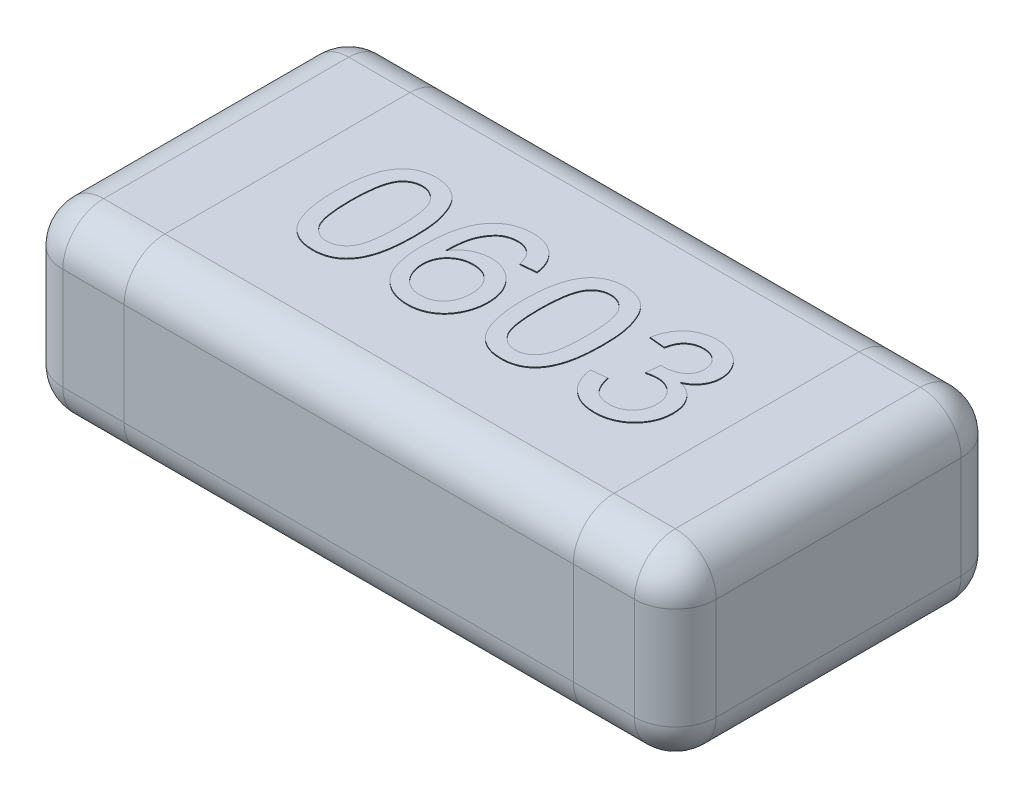
from build123d import *

# Parameters (mm, degrees)
SKETCH1_W      = 1.6
SKETCH1_H      = 0.8
EXTRUDE1_DEPTH = 0.45
FILLET1_R      = 0.1
EXTRUDE2_DEPTH = 0.002


with BuildPart() as part:
    # Sketch1 → Extrude1 (new body)
    with BuildSketch(Plane(origin=(0, 0, 0), x_dir=(1, 0, 0), z_dir=(0, 1, 0))):
        Rectangle(SKETCH1_W, SKETCH1_H)
    extrude(amount=EXTRUDE1_DEPTH)

    # Fillet1
    fillet1_edges = [part.edges().sort_by_distance(p)[0] for p in [
        (0.8, 0.45, 0),
        (0, 0.45, -0.4),
        (-0.8, 0.45, 0),
        (0, 0, -0.4),
        (0.8, 0, 0),
        (0, 0, 0.4),
        (-0.8, 0, 0),
        (0, 0.45, 0.4),
        (-0.8, 0.225, -0.4),
        (0.8, 0.225, -0.4),
        (0.8, 0.225, 0.4),
        (-0.8, 0.225, 0.4),
    ]]
    fillet(fillet1_edges, radius=FILLET1_R)

    # Sketch3 → Extrude2 (add)
    with BuildSketch(Plane(origin=(0, 0.45, 0), x_dir=(1, 0, 0), z_dir=(0, 1, 0))):
        with BuildLine():
            add(Edge.make_bspline(
                [(-0.430769231, -0.002043269), (-0.430730481, 0.002244006), (-0.430654586, 0.010640973), (-0.430183834, 0.022927244), (-0.42936194, 0.034595007), (-0.428135078, 0.045634129), (-0.426682243, 0.056069528), (-0.424793549, 0.06588631), (-0.422668494, 0.075106502), (-0.420118809, 0.083720493), (-0.41731754, 0.091802347), (-0.414139411, 0.0993391), (-0.410563584, 0.106322761), (-0.40676579, 0.112825754), (-0.402546105, 0.118746931), (-0.39815922, 0.124252464), (-0.393286323, 0.129140445), (-0.388130039, 0.13353664), (-0.382614442, 0.137416027), (-0.376768712, 0.140763469), (-0.370615345, 0.143719019), (-0.364037062, 0.145943957), (-0.357170429, 0.147757753), (-0.349962588, 0.149092003), (-0.342405598, 0.149878588), (-0.337241458, 0.149959072), (-0.334615385, 0.15)],
                knots=[0, 0, 0, 0, 1.2862e-05, 2.5191e-05, 3.688e-05, 4.7943e-05, 5.8507e-05, 6.8478e-05, 7.7924e-05, 8.6881e-05, 9.5415e-05, 0.000103574, 0.000111395, 0.00011894, 0.000126142, 0.000133191, 0.000140033, 0.000146812, 0.000153498, 0.000160229, 0.000167003, 0.000173941, 0.000181025, 0.000188297, 0.00019591, 0.000203786, 0.000203786, 0.000203786, 0.000203786], degree=3))
            add(Edge.make_bspline(
                [(-0.334615385, 0.15), (-0.330762593, 0.149886731), (-0.32319363, 0.149664209), (-0.312142905, 0.147849358), (-0.301728309, 0.144744777), (-0.291956608, 0.140556563), (-0.282994848, 0.135236725), (-0.274991618, 0.128769652), (-0.268033247, 0.121223246), (-0.262195674, 0.112508085), (-0.257093053, 0.102864591), (-0.252559996, 0.092249481), (-0.248462244, 0.080674651), (-0.24555439, 0.070313561), (-0.243480221, 0.061369501), (-0.242107285, 0.053992694), (-0.240967473, 0.046033077), (-0.240094223, 0.037509907), (-0.239377743, 0.028432744), (-0.238824437, 0.018795935), (-0.238543578, 0.008575397), (-0.238489398, 0.001562641), (-0.238461538, -0.002043269)],
                knots=[0, 0, 0, 0, 1.1554e-05, 2.2698e-05, 3.348e-05, 4.4085e-05, 5.4516e-05, 6.4643e-05, 7.485e-05, 8.5185e-05, 9.602e-05, 0.000107541, 0.000119781, 0.000132832, 0.000139801, 0.000147321, 0.000155335, 0.000163916, 0.000173019, 0.00018265, 0.000192871, 0.000203689, 0.000203689, 0.000203689, 0.000203689], degree=3))
            add(Edge.make_bspline(
                [(-0.238461538, -0.002043269), (-0.238501014, -0.006310407), (-0.238578138, -0.0146471), (-0.239036276, -0.026834856), (-0.239907695, -0.038414591), (-0.240979992, -0.049412832), (-0.242602154, -0.059800218), (-0.24435012, -0.069620882), (-0.246511923, -0.07883023), (-0.249034239, -0.087432298), (-0.251874941, -0.095472571), (-0.254990209, -0.103011813), (-0.258440668, -0.110044871), (-0.262329015, -0.11650315), (-0.266477343, -0.122472371), (-0.270916032, -0.127974928), (-0.275739189, -0.132931621), (-0.280941938, -0.137314631), (-0.28641881, -0.141262812), (-0.292278751, -0.144643304), (-0.298496114, -0.147443983), (-0.305029358, -0.149838424), (-0.311944772, -0.15159293), (-0.319187822, -0.152935977), (-0.326785196, -0.153726861), (-0.331969311, -0.153805841), (-0.334615385, -0.153846154)],
                knots=[0, 0, 0, 0, 1.2802e-05, 2.5011e-05, 3.658e-05, 4.7637e-05, 5.815e-05, 6.811e-05, 7.7556e-05, 8.6513e-05, 9.499e-05, 0.000103126, 0.000110974, 0.000118467, 0.000125719, 0.000132767, 0.000139652, 0.000146431, 0.000153152, 0.000159883, 0.000166686, 0.000173587, 0.000180729, 0.000188061, 0.000195673, 0.00020361, 0.00020361, 0.00020361, 0.00020361], degree=3))
            add(Edge.make_bspline(
                [(-0.334615385, -0.153846154), (-0.338084694, -0.153747192), (-0.344848894, -0.153554242), (-0.354727508, -0.152243272), (-0.363999114, -0.149935902), (-0.372741914, -0.146841394), (-0.380857634, -0.142702311), (-0.388385026, -0.137666308), (-0.395475345, -0.131850554), (-0.399556964, -0.127262057), (-0.401622596, -0.124939904)],
                knots=[0, 0, 0, 0, 1.0408e-05, 2.0292e-05, 2.9825e-05, 3.9025e-05, 4.8056e-05, 5.7073e-05, 6.616e-05, 7.5471e-05, 7.5471e-05, 7.5471e-05, 7.5471e-05], degree=3))
            add(Edge.make_bspline(
                [(-0.401622596, -0.124939904), (-0.404000186, -0.121510195), (-0.408902879, -0.11443799), (-0.414641055, -0.102379223), (-0.41975961, -0.089104214), (-0.423776737, -0.074352508), (-0.426923149, -0.058241513), (-0.429195644, -0.040739616), (-0.430481652, -0.021854376), (-0.430671207, -0.008796046), (-0.430769231, -0.002043269)],
                knots=[0, 0, 0, 0, 1.2501e-05, 2.5778e-05, 3.993e-05, 5.5152e-05, 7.157e-05, 8.9147e-05, 0.000108063, 0.000128321, 0.000128321, 0.000128321, 0.000128321], degree=3))
        make_face()
        with BuildLine():
            add(Edge.make_bspline(
                [(-0.392307692, -0.001923077), (-0.392269503, -0.007693168), (-0.3921964, -0.018738399), (-0.391432655, -0.034518417), (-0.390117899, -0.048754147), (-0.388379705, -0.061425879), (-0.386084585, -0.072550754), (-0.383202791, -0.082100422), (-0.379954324, -0.090189501), (-0.375934407, -0.096717734), (-0.371533042, -0.102039196), (-0.366988934, -0.106615825), (-0.362195175, -0.110505855), (-0.357183043, -0.113749347), (-0.351874773, -0.116205105), (-0.346328409, -0.117985045), (-0.340542745, -0.119009373), (-0.336602445, -0.119156549), (-0.334615385, -0.119230769)],
                knots=[0, 0, 0, 0, 1.7309e-05, 3.3134e-05, 4.7378e-05, 6.0186e-05, 7.1489e-05, 8.1413e-05, 9.0085e-05, 9.7558e-05, 0.000104306, 0.000110765, 0.000116876, 0.000122794, 0.000128628, 0.000134368, 0.000140227, 0.000146187, 0.000146187, 0.000146187, 0.000146187], degree=3))
            add(Edge.make_bspline(
                [(-0.334615385, -0.119230769), (-0.332628822, -0.119154928), (-0.328689509, -0.119004535), (-0.322890476, -0.118002795), (-0.317365692, -0.116131225), (-0.312065336, -0.11368414), (-0.307016775, -0.110514577), (-0.30224656, -0.106609854), (-0.297678514, -0.102035942), (-0.29329692, -0.096652628), (-0.289307629, -0.090094213), (-0.285998225, -0.082011723), (-0.283161342, -0.072445331), (-0.280853628, -0.061326124), (-0.279108264, -0.048674427), (-0.277801457, -0.03447818), (-0.2770326, -0.018718466), (-0.276960704, -0.007693194), (-0.276923077, -0.001923077)],
                knots=[0, 0, 0, 0, 5.96e-06, 1.1819e-05, 1.7578e-05, 2.3412e-05, 2.9298e-05, 3.5408e-05, 4.1867e-05, 4.8662e-05, 5.6186e-05, 6.4803e-05, 7.4784e-05, 8.6088e-05, 9.8836e-05, 0.00011308, 0.000128845, 0.000146154, 0.000146154, 0.000146154, 0.000146154], degree=3))
            add(Edge.make_bspline(
                [(-0.276923077, -0.001923077), (-0.276959499, 0.003726983), (-0.277029283, 0.014552283), (-0.27781797, 0.030028299), (-0.279053912, 0.044025088), (-0.280744486, 0.056555555), (-0.282991257, 0.067606095), (-0.285716284, 0.077200235), (-0.288963562, 0.085317512), (-0.292824563, 0.092039466), (-0.29712263, 0.097553292), (-0.301612368, 0.102325988), (-0.306406022, 0.10638501), (-0.31158852, 0.109641218), (-0.316992821, 0.112268205), (-0.322743102, 0.114076165), (-0.328782842, 0.115186918), (-0.332927837, 0.115317963), (-0.335036058, 0.115384615)],
                knots=[0, 0, 0, 0, 1.6949e-05, 3.2473e-05, 4.6473e-05, 5.9094e-05, 7.0385e-05, 8.0274e-05, 8.8979e-05, 9.6545e-05, 0.000103444, 0.000109906, 0.000116177, 0.000122229, 0.000128223, 0.000134153, 0.000140259, 0.000146579, 0.000146579, 0.000146579, 0.000146579], degree=3))
            add(Edge.make_bspline(
                [(-0.335036058, 0.115384615), (-0.337022993, 0.115332466), (-0.340940974, 0.115229635), (-0.346677413, 0.114248109), (-0.352113768, 0.112606778), (-0.357312323, 0.110383437), (-0.362143298, 0.107391258), (-0.366798279, 0.103897677), (-0.371059245, 0.099641138), (-0.373626865, 0.096459016), (-0.374939904, 0.094831731)],
                knots=[0, 0, 0, 0, 5.957e-06, 1.1747e-05, 1.7393e-05, 2.2965e-05, 2.8654e-05, 3.4399e-05, 4.0391e-05, 4.6662e-05, 4.6662e-05, 4.6662e-05, 4.6662e-05], degree=3))
            add(Edge.make_bspline(
                [(-0.374939904, 0.094831731), (-0.376369403, 0.092441753), (-0.379388204, 0.087394622), (-0.382766067, 0.078622501), (-0.385749937, 0.068597636), (-0.388206652, 0.057165788), (-0.389983913, 0.044346567), (-0.391386991, 0.03015486), (-0.392115838, 0.014570853), (-0.392241977, 0.003726591), (-0.392307692, -0.001923077)],
                knots=[0, 0, 0, 0, 8.341e-06, 1.7615e-05, 2.8091e-05, 3.9714e-05, 5.2649e-05, 6.6899e-05, 8.2483e-05, 9.9433e-05, 9.9433e-05, 9.9433e-05, 9.9433e-05], degree=3))
        make_face(mode=Mode.SUBTRACT)
        with BuildLine():
            Line((-0.011538462, 0.073076923), (-0.05, 0.069230769))
            add(Edge.make_bspline(
                [(-0.05, 0.069230769), (-0.050829969, 0.072538667), (-0.052392258, 0.078765275), (-0.055668364, 0.087210729), (-0.059278562, 0.094354147), (-0.06241504, 0.09820068), (-0.063882212, 0.1)],
                knots=[0, 0, 0, 0, 1.022e-05, 1.9238e-05, 2.7142e-05, 3.4089e-05, 3.4089e-05, 3.4089e-05, 3.4089e-05], degree=3))
            add(Edge.make_bspline(
                [(-0.063882212, 0.1), (-0.065141608, 0.101227235), (-0.06761855, 0.103640922), (-0.071684786, 0.10678718), (-0.075971272, 0.109452847), (-0.080490964, 0.111612442), (-0.085219443, 0.113318398), (-0.090176297, 0.114511805), (-0.095350295, 0.115250592), (-0.098875729, 0.115339561), (-0.100661058, 0.115384615)],
                knots=[0, 0, 0, 0, 5.272e-06, 1.0369e-05, 1.5389e-05, 2.0388e-05, 2.5369e-05, 3.0441e-05, 3.5659e-05, 4.1013e-05, 4.1013e-05, 4.1013e-05, 4.1013e-05], degree=3))
            add(Edge.make_bspline(
                [(-0.100661058, 0.115384615), (-0.103555382, 0.115291422), (-0.109274441, 0.115107275), (-0.117665322, 0.113304494), (-0.125815226, 0.110606344), (-0.130864393, 0.107871213), (-0.133413462, 0.106490385)],
                knots=[0, 0, 0, 0, 8.671e-06, 1.7133e-05, 2.5647e-05, 3.4328e-05, 3.4328e-05, 3.4328e-05, 3.4328e-05], degree=3))
            add(Edge.make_bspline(
                [(-0.133413462, 0.106490385), (-0.135920312, 0.104413394), (-0.141066276, 0.10014983), (-0.147781823, 0.092271657), (-0.153787447, 0.08309911), (-0.158216704, 0.074535839), (-0.161333874, 0.066858114), (-0.16334989, 0.060278069), (-0.165072325, 0.053008475), (-0.16650721, 0.045063026), (-0.167617002, 0.036435278), (-0.168544565, 0.027119753), (-0.169057587, 0.017092829), (-0.16917185, 0.010176786), (-0.169230769, 0.006610577)],
                knots=[0, 0, 0, 0, 9.752e-06, 2.0019e-05, 3.0903e-05, 4.2594e-05, 4.8877e-05, 5.5739e-05, 6.3217e-05, 7.1279e-05, 7.9949e-05, 8.9307e-05, 9.9358e-05, 0.000110058, 0.000110058, 0.000110058, 0.000110058], degree=3))
            add(Edge.make_bspline(
                [(-0.169230769, 0.006610577), (-0.166963206, 0.009796435), (-0.162524314, 0.016032946), (-0.154693772, 0.024190765), (-0.146143182, 0.031086712), (-0.136862984, 0.036592663), (-0.127095327, 0.040859911), (-0.1170556, 0.04393058), (-0.106761399, 0.045815439), (-0.099827562, 0.04604047), (-0.096334135, 0.046153846)],
                knots=[0, 0, 0, 0, 1.1719e-05, 2.294e-05, 3.3799e-05, 4.458e-05, 5.5209e-05, 6.5703e-05, 7.6018e-05, 8.6492e-05, 8.6492e-05, 8.6492e-05, 8.6492e-05], degree=3))
            add(Edge.make_bspline(
                [(-0.096334135, 0.046153846), (-0.093325438, 0.046072896), (-0.087381185, 0.045912965), (-0.078627599, 0.044645582), (-0.070235491, 0.042428842), (-0.062132133, 0.03954103), (-0.054473247, 0.035598019), (-0.047071912, 0.0309898), (-0.040099544, 0.025382127), (-0.033467899, 0.019081266), (-0.027430044, 0.012076111), (-0.022086114, 0.004536569), (-0.017632827, -0.003555431), (-0.014021726, -0.012145696), (-0.011195409, -0.021202968), (-0.009141754, -0.030752967), (-0.007939571, -0.040814567), (-0.007775833, -0.047693081), (-0.007692308, -0.051201923)],
                knots=[0, 0, 0, 0, 9.024e-06, 1.7829e-05, 2.6458e-05, 3.5032e-05, 4.3579e-05, 5.2249e-05, 6.1146e-05, 7.037e-05, 7.9659e-05, 8.8846e-05, 9.8045e-05, 0.000107309, 0.000116756, 0.000126468, 0.000136576, 0.000147101, 0.000147101, 0.000147101, 0.000147101], degree=3))
            add(Edge.make_bspline(
                [(-0.007692308, -0.051201923), (-0.007841956, -0.055839129), (-0.008137282, -0.064990544), (-0.010507741, -0.078467226), (-0.014327384, -0.091457445), (-0.018896643, -0.101744572), (-0.023094599, -0.109625611), (-0.026659155, -0.115137959), (-0.030470671, -0.120318178), (-0.03445695, -0.12523755), (-0.038907119, -0.129670926), (-0.043551384, -0.133827203), (-0.048543256, -0.137562688), (-0.053735918, -0.141001671), (-0.059227464, -0.143983621), (-0.064858103, -0.146633405), (-0.070674187, -0.148890534), (-0.076694495, -0.150662761), (-0.082888194, -0.152128961), (-0.0892759, -0.153137108), (-0.095840801, -0.153758859), (-0.100279044, -0.15381683), (-0.102524038, -0.153846154)],
                knots=[0, 0, 0, 0, 1.3904e-05, 2.744e-05, 4.0921e-05, 5.443e-05, 6.1126e-05, 6.7694e-05, 7.4101e-05, 8.0418e-05, 8.6665e-05, 9.2923e-05, 9.9101e-05, 0.000105352, 0.000111591, 0.000117829, 0.000124012, 0.000130286, 0.000136642, 0.000143093, 0.000149671, 0.000156404, 0.000156404, 0.000156404, 0.000156404], degree=3))
            add(Edge.make_bspline(
                [(-0.102524038, -0.153846154), (-0.106315414, -0.153741017), (-0.113750967, -0.153534825), (-0.124633988, -0.151950766), (-0.134967892, -0.14930358), (-0.144774661, -0.145602515), (-0.15408417, -0.140929997), (-0.162804676, -0.135072673), (-0.170984431, -0.128204222), (-0.178629742, -0.120284809), (-0.185561739, -0.11114027), (-0.191486135, -0.100584666), (-0.196534247, -0.088710395), (-0.200665687, -0.075484787), (-0.203791995, -0.060894011), (-0.206043068, -0.044969404), (-0.207427453, -0.027708685), (-0.207601959, -0.015747884), (-0.207692308, -0.009555288)],
                knots=[0, 0, 0, 0, 1.1371e-05, 2.2301e-05, 3.2912e-05, 4.3315e-05, 5.3689e-05, 6.409e-05, 7.4754e-05, 8.5677e-05, 9.7048e-05, 0.000109078, 0.000121893, 0.000135692, 0.00015058, 0.000166609, 0.000183912, 0.000202488, 0.000202488, 0.000202488, 0.000202488], degree=3))
            add(Edge.make_bspline(
                [(-0.207692308, -0.009555288), (-0.207677327, -0.006029025), (-0.207647779, 0.000925972), (-0.207172972, 0.011161994), (-0.20662831, 0.021047347), (-0.205695117, 0.030542594), (-0.204593262, 0.039690441), (-0.203114587, 0.048437091), (-0.201526668, 0.056850531), (-0.199596082, 0.06486452), (-0.197443951, 0.072554447), (-0.194966773, 0.079835817), (-0.19235026, 0.086802839), (-0.18938188, 0.093345608), (-0.186218279, 0.099570683), (-0.18272138, 0.105362867), (-0.179054084, 0.1108546), (-0.176346734, 0.114240976), (-0.175, 0.115925481)],
                knots=[0, 0, 0, 0, 1.0578e-05, 2.0863e-05, 3.0737e-05, 4.0275e-05, 4.948e-05, 5.8372e-05, 6.6882e-05, 7.5161e-05, 8.3094e-05, 9.0829e-05, 9.8228e-05, 0.00010541, 0.000112371, 0.000119163, 0.000125697, 0.000132165, 0.000132165, 0.000132165, 0.000132165], degree=3))
            add(Edge.make_bspline(
                [(-0.175, 0.115925481), (-0.17257725, 0.118650597), (-0.167801785, 0.124022054), (-0.159632467, 0.130960705), (-0.150927369, 0.136887379), (-0.141547658, 0.14167562), (-0.131565021, 0.145408685), (-0.120973202, 0.14811856), (-0.109742644, 0.149690101), (-0.102068264, 0.149895026), (-0.098137019, 0.15)],
                knots=[0, 0, 0, 0, 1.0928e-05, 2.154e-05, 3.2057e-05, 4.2459e-05, 5.3051e-05, 6.3969e-05, 7.5196e-05, 8.6987e-05, 8.6987e-05, 8.6987e-05, 8.6987e-05], degree=3))
            add(Edge.make_bspline(
                [(-0.098137019, 0.15), (-0.095209771, 0.149948255), (-0.089458956, 0.149846599), (-0.081032545, 0.148871193), (-0.073017547, 0.147240948), (-0.065396111, 0.145041931), (-0.058212554, 0.142114758), (-0.051384057, 0.138645741), (-0.044979959, 0.134472732), (-0.039046622, 0.129652743), (-0.03356935, 0.124322407), (-0.028663433, 0.118436964), (-0.024347357, 0.112069766), (-0.020587369, 0.10520757), (-0.017417069, 0.097882861), (-0.014814096, 0.090064157), (-0.012835662, 0.081753468), (-0.011976855, 0.076009194), (-0.011538462, 0.073076923)],
                knots=[0, 0, 0, 0, 8.779e-06, 1.7247e-05, 2.5403e-05, 3.3295e-05, 4.1006e-05, 4.864e-05, 5.624e-05, 6.389e-05, 7.1539e-05, 7.9134e-05, 8.6834e-05, 9.458e-05, 0.000102574, 0.000110746, 0.000119273, 0.000128165, 0.000128165, 0.000128165, 0.000128165], degree=3))
        make_face()
        with BuildLine():
            add(Edge.make_bspline(
                [(-0.169230769, -0.050420673), (-0.16912379, -0.053432194), (-0.168911236, -0.0594157), (-0.16728544, -0.068297189), (-0.1646304, -0.076962701), (-0.160991638, -0.085315996), (-0.156498437, -0.093077055), (-0.151161561, -0.099953889), (-0.145096853, -0.105845529), (-0.138336906, -0.110764759), (-0.130897587, -0.114545052), (-0.122912136, -0.117282967), (-0.114371013, -0.118937772), (-0.108480992, -0.119131628), (-0.10546875, -0.119230769)],
                knots=[0, 0, 0, 0, 9.031e-06, 1.7943e-05, 2.6992e-05, 3.6169e-05, 4.5219e-05, 5.3826e-05, 6.2198e-05, 7.0505e-05, 7.881e-05, 8.7134e-05, 9.5761e-05, 0.000104792, 0.000104792, 0.000104792, 0.000104792], degree=3))
            add(Edge.make_bspline(
                [(-0.10546875, -0.119230769), (-0.103322185, -0.119172715), (-0.099132279, -0.1190594), (-0.092997577, -0.118181315), (-0.087144393, -0.116831083), (-0.08160662, -0.114836124), (-0.076391771, -0.112290008), (-0.071472771, -0.109191217), (-0.0668528, -0.105530475), (-0.062587718, -0.1013145), (-0.058733006, -0.096625578), (-0.055383772, -0.091492483), (-0.052426086, -0.085999667), (-0.050201434, -0.080012147), (-0.048388665, -0.073683317), (-0.047055933, -0.066953335), (-0.04627348, -0.059814476), (-0.046194301, -0.05490983), (-0.046153846, -0.052403846)],
                knots=[0, 0, 0, 0, 6.437e-06, 1.2565e-05, 1.8556e-05, 2.443e-05, 3.0181e-05, 3.5934e-05, 4.1837e-05, 4.7829e-05, 5.3893e-05, 6.001e-05, 6.6193e-05, 7.2565e-05, 7.9128e-05, 8.5928e-05, 9.3122e-05, 0.000100638, 0.000100638, 0.000100638, 0.000100638], degree=3))
            add(Edge.make_bspline(
                [(-0.046153846, -0.052403846), (-0.046191368, -0.049997387), (-0.046264746, -0.045291251), (-0.047090406, -0.038423999), (-0.048293195, -0.031932012), (-0.050139616, -0.025869914), (-0.052405781, -0.020173529), (-0.055245261, -0.014885466), (-0.058553792, -0.009960784), (-0.062432908, -0.005529883), (-0.066674999, -0.001493073), (-0.071333938, 0.002013282), (-0.076353811, 0.00497459), (-0.081752727, 0.007398919), (-0.087540857, 0.009256882), (-0.093706214, 0.010544495), (-0.100214109, 0.011443306), (-0.104684279, 0.011506257), (-0.106971154, 0.011538462)],
                knots=[0, 0, 0, 0, 7.216e-06, 1.4111e-05, 2.0723e-05, 2.6997e-05, 3.309e-05, 3.9086e-05, 4.497e-05, 5.0849e-05, 5.6716e-05, 6.2509e-05, 6.8302e-05, 7.4165e-05, 8.0228e-05, 8.6499e-05, 9.3043e-05, 9.9899e-05, 9.9899e-05, 9.9899e-05, 9.9899e-05], degree=3))
            add(Edge.make_bspline(
                [(-0.106971154, 0.011538462), (-0.10909795, 0.011505232), (-0.113289005, 0.01143975), (-0.119435222, 0.010533926), (-0.125358927, 0.009243732), (-0.13103647, 0.007366681), (-0.136469803, 0.004949397), (-0.141657721, 0.002009058), (-0.146555172, -0.001538568), (-0.151206813, -0.005511501), (-0.15545138, -0.009924881), (-0.159175366, -0.014699634), (-0.162212805, -0.019866478), (-0.164868019, -0.02529901), (-0.166813402, -0.031125292), (-0.168197567, -0.03726721), (-0.169055714, -0.0437259), (-0.169171509, -0.048154362), (-0.169230769, -0.050420673)],
                knots=[0, 0, 0, 0, 6.375e-06, 1.2562e-05, 1.8598e-05, 2.4546e-05, 3.0465e-05, 3.6413e-05, 4.24e-05, 4.858e-05, 5.4743e-05, 6.0741e-05, 6.6698e-05, 7.2692e-05, 7.885e-05, 8.5075e-05, 9.156e-05, 9.8358e-05, 9.8358e-05, 9.8358e-05, 9.8358e-05], degree=3))
        make_face(mode=Mode.SUBTRACT)
        with BuildLine():
            add(Edge.make_bspline(
                [(0.030769231, -0.002043269), (0.030807981, 0.002244006), (0.030883876, 0.010640973), (0.031354627, 0.022927244), (0.032176522, 0.034595007), (0.033403384, 0.045634129), (0.034856218, 0.056069528), (0.036744912, 0.06588631), (0.038869967, 0.075106502), (0.041419652, 0.083720493), (0.044220921, 0.091802347), (0.047399051, 0.0993391), (0.050974877, 0.106322761), (0.054772671, 0.112825754), (0.058992356, 0.118746931), (0.063379241, 0.124252464), (0.068252138, 0.129140445), (0.073408422, 0.13353664), (0.07892402, 0.137416027), (0.084769749, 0.140763469), (0.090923117, 0.143719019), (0.097501399, 0.145943957), (0.104368033, 0.147757753), (0.111575873, 0.149092003), (0.119132863, 0.149878588), (0.124297003, 0.149959072), (0.126923077, 0.15)],
                knots=[0, 0, 0, 0, 1.2862e-05, 2.5191e-05, 3.688e-05, 4.7943e-05, 5.8507e-05, 6.8478e-05, 7.7924e-05, 8.6881e-05, 9.5415e-05, 0.000103574, 0.000111395, 0.00011894, 0.000126142, 0.000133191, 0.000140033, 0.000146812, 0.000153498, 0.000160229, 0.000167003, 0.000173941, 0.000181025, 0.000188297, 0.00019591, 0.000203786, 0.000203786, 0.000203786, 0.000203786], degree=3))
            add(Edge.make_bspline(
                [(0.126923077, 0.15), (0.130775868, 0.149886731), (0.138344831, 0.149664209), (0.149395556, 0.147849358), (0.159810153, 0.144744777), (0.169581854, 0.140556563), (0.178543614, 0.135236725), (0.186546843, 0.128769652), (0.193505214, 0.121223246), (0.199342787, 0.112508085), (0.204445409, 0.102864591), (0.208978466, 0.092249481), (0.213076217, 0.080674651), (0.215984071, 0.070313561), (0.218058241, 0.061369501), (0.219431176, 0.053992694), (0.220570988, 0.046033077), (0.221444238, 0.037509907), (0.222160719, 0.028432744), (0.222714024, 0.018795935), (0.222994883, 0.008575397), (0.223049064, 0.001562641), (0.223076923, -0.002043269)],
                knots=[0, 0, 0, 0, 1.1554e-05, 2.2698e-05, 3.348e-05, 4.4085e-05, 5.4516e-05, 6.4643e-05, 7.485e-05, 8.5185e-05, 9.602e-05, 0.000107541, 0.000119781, 0.000132832, 0.000139801, 0.000147321, 0.000155335, 0.000163916, 0.000173019, 0.00018265, 0.000192871, 0.000203689, 0.000203689, 0.000203689, 0.000203689], degree=3))
            add(Edge.make_bspline(
                [(0.223076923, -0.002043269), (0.223037447, -0.006310407), (0.222960323, -0.0146471), (0.222502186, -0.026834856), (0.221630766, -0.038414591), (0.220558469, -0.049412832), (0.218936308, -0.059800218), (0.217188341, -0.069620882), (0.215026538, -0.07883023), (0.212504222, -0.087432298), (0.209663521, -0.095472571), (0.206548253, -0.103011813), (0.203097794, -0.110044871), (0.199209446, -0.11650315), (0.195061119, -0.122472371), (0.190622429, -0.127974928), (0.185799273, -0.132931621), (0.180596523, -0.137314631), (0.175119652, -0.141262812), (0.16925971, -0.144643304), (0.163042348, -0.147443983), (0.156509104, -0.149838424), (0.149593689, -0.15159293), (0.142350639, -0.152935977), (0.134753266, -0.153726861), (0.129569151, -0.153805841), (0.126923077, -0.153846154)],
                knots=[0, 0, 0, 0, 1.2802e-05, 2.5011e-05, 3.658e-05, 4.7637e-05, 5.815e-05, 6.811e-05, 7.7556e-05, 8.6513e-05, 9.499e-05, 0.000103126, 0.000110974, 0.000118467, 0.000125719, 0.000132767, 0.000139652, 0.000146431, 0.000153152, 0.000159883, 0.000166686, 0.000173587, 0.000180729, 0.000188061, 0.000195673, 0.00020361, 0.00020361, 0.00020361, 0.00020361], degree=3))
            add(Edge.make_bspline(
                [(0.126923077, -0.153846154), (0.123453767, -0.153747192), (0.116689568, -0.153554242), (0.106810954, -0.152243272), (0.097539347, -0.149935902), (0.088796548, -0.146841394), (0.080680827, -0.142702311), (0.073153436, -0.137666308), (0.066063116, -0.131850554), (0.061981497, -0.127262057), (0.059915865, -0.124939904)],
                knots=[0, 0, 0, 0, 1.0408e-05, 2.0292e-05, 2.9825e-05, 3.9025e-05, 4.8056e-05, 5.7073e-05, 6.616e-05, 7.5471e-05, 7.5471e-05, 7.5471e-05, 7.5471e-05], degree=3))
            add(Edge.make_bspline(
                [(0.059915865, -0.124939904), (0.057538275, -0.121510195), (0.052635583, -0.11443799), (0.046897407, -0.102379223), (0.041778852, -0.089104214), (0.037761725, -0.074352508), (0.034615313, -0.058241513), (0.032342818, -0.040739616), (0.031056809, -0.021854376), (0.030867254, -0.008796046), (0.030769231, -0.002043269)],
                knots=[0, 0, 0, 0, 1.2501e-05, 2.5778e-05, 3.993e-05, 5.5152e-05, 7.157e-05, 8.9147e-05, 0.000108063, 0.000128321, 0.000128321, 0.000128321, 0.000128321], degree=3))
        make_face()
        with BuildLine():
            add(Edge.make_bspline(
                [(0.069230769, -0.001923077), (0.069268958, -0.007693168), (0.069342061, -0.018738399), (0.070105807, -0.034518417), (0.071420563, -0.048754147), (0.073158757, -0.061425879), (0.075453876, -0.072550754), (0.07833567, -0.082100422), (0.081584138, -0.090189501), (0.085604055, -0.096717734), (0.090005419, -0.102039196), (0.094549528, -0.106615825), (0.099343287, -0.110505855), (0.104355418, -0.113749347), (0.109663688, -0.116205105), (0.115210052, -0.117985045), (0.120995717, -0.119009373), (0.124936017, -0.119156549), (0.126923077, -0.119230769)],
                knots=[0, 0, 0, 0, 1.7309e-05, 3.3134e-05, 4.7378e-05, 6.0186e-05, 7.1489e-05, 8.1413e-05, 9.0085e-05, 9.7558e-05, 0.000104306, 0.000110765, 0.000116876, 0.000122794, 0.000128628, 0.000134368, 0.000140227, 0.000146187, 0.000146187, 0.000146187, 0.000146187], degree=3))
            add(Edge.make_bspline(
                [(0.126923077, -0.119230769), (0.128909639, -0.119154928), (0.132848953, -0.119004535), (0.138647986, -0.118002795), (0.14417277, -0.116131225), (0.149473125, -0.11368414), (0.154521686, -0.110514577), (0.159291902, -0.106609854), (0.163859948, -0.102035942), (0.168241542, -0.096652628), (0.172230832, -0.090094213), (0.175540237, -0.082011723), (0.17837712, -0.072445331), (0.180684833, -0.061326124), (0.182430197, -0.048674427), (0.183737005, -0.03447818), (0.184505861, -0.018718466), (0.184577757, -0.007693194), (0.184615385, -0.001923077)],
                knots=[0, 0, 0, 0, 5.96e-06, 1.1819e-05, 1.7578e-05, 2.3412e-05, 2.9298e-05, 3.5408e-05, 4.1867e-05, 4.8662e-05, 5.6186e-05, 6.4803e-05, 7.4784e-05, 8.6088e-05, 9.8836e-05, 0.00011308, 0.000128845, 0.000146154, 0.000146154, 0.000146154, 0.000146154], degree=3))
            add(Edge.make_bspline(
                [(0.184615385, -0.001923077), (0.184578962, 0.003726983), (0.184509178, 0.014552283), (0.183720492, 0.030028299), (0.182484549, 0.044025088), (0.180793976, 0.056555555), (0.178547205, 0.067606095), (0.175822177, 0.077200235), (0.1725749, 0.085317512), (0.168713899, 0.092039466), (0.164415832, 0.097553292), (0.159926094, 0.102325988), (0.15513244, 0.10638501), (0.149949942, 0.109641218), (0.144545641, 0.112268205), (0.13879536, 0.114076165), (0.13275562, 0.115186918), (0.128610625, 0.115317963), (0.126502404, 0.115384615)],
                knots=[0, 0, 0, 0, 1.6949e-05, 3.2473e-05, 4.6473e-05, 5.9094e-05, 7.0385e-05, 8.0274e-05, 8.8979e-05, 9.6545e-05, 0.000103444, 0.000109906, 0.000116177, 0.000122229, 0.000128223, 0.000134153, 0.000140259, 0.000146579, 0.000146579, 0.000146579, 0.000146579], degree=3))
            add(Edge.make_bspline(
                [(0.126502404, 0.115384615), (0.124515469, 0.115332466), (0.120597487, 0.115229635), (0.114861049, 0.114248109), (0.109424694, 0.112606778), (0.104226139, 0.110383437), (0.099395163, 0.107391258), (0.094740182, 0.103897677), (0.090479217, 0.099641138), (0.087911597, 0.096459016), (0.086598558, 0.094831731)],
                knots=[0, 0, 0, 0, 5.957e-06, 1.1747e-05, 1.7393e-05, 2.2965e-05, 2.8654e-05, 3.4399e-05, 4.0391e-05, 4.6662e-05, 4.6662e-05, 4.6662e-05, 4.6662e-05], degree=3))
            add(Edge.make_bspline(
                [(0.086598558, 0.094831731), (0.085169059, 0.092441753), (0.082150258, 0.087394622), (0.078772395, 0.078622501), (0.075788524, 0.068597636), (0.07333181, 0.057165788), (0.071554549, 0.044346567), (0.07015147, 0.03015486), (0.069422623, 0.014570853), (0.069296485, 0.003726591), (0.069230769, -0.001923077)],
                knots=[0, 0, 0, 0, 8.341e-06, 1.7615e-05, 2.8091e-05, 3.9714e-05, 5.2649e-05, 6.6899e-05, 8.2483e-05, 9.9433e-05, 9.9433e-05, 9.9433e-05, 9.9433e-05], degree=3))
        make_face(mode=Mode.SUBTRACT)
        with BuildLine():
            Line((0.261538462, -0.069230769), (0.3, -0.065384615))
            add(Edge.make_bspline(
                [(0.3, -0.065384615), (0.300512738, -0.067695612), (0.301504849, -0.07216722), (0.303413791, -0.078573263), (0.305430053, -0.084519503), (0.307929602, -0.089872937), (0.310368618, -0.094852499), (0.313234831, -0.099252438), (0.316297435, -0.103187554), (0.319613048, -0.106643235), (0.323219876, -0.109618998), (0.327069832, -0.112222951), (0.331244339, -0.114397603), (0.335711436, -0.116119397), (0.340433499, -0.117513204), (0.345436191, -0.118536651), (0.350745964, -0.119146331), (0.354385383, -0.119202164), (0.35625, -0.119230769)],
                knots=[0, 0, 0, 0, 7.099e-06, 1.3736e-05, 2.0046e-05, 2.591e-05, 3.1447e-05, 3.6665e-05, 4.163e-05, 4.639e-05, 5.0999e-05, 5.5633e-05, 6.031e-05, 6.5086e-05, 6.9973e-05, 7.5065e-05, 8.0387e-05, 8.5979e-05, 8.5979e-05, 8.5979e-05, 8.5979e-05], degree=3))
            add(Edge.make_bspline(
                [(0.35625, -0.119230769), (0.35843713, -0.119199586), (0.362708599, -0.119138685), (0.368932833, -0.118224941), (0.374856289, -0.116970282), (0.380394456, -0.115002906), (0.385624449, -0.112598409), (0.390516472, -0.109626961), (0.395104012, -0.106137736), (0.399296582, -0.102107003), (0.403045987, -0.097673067), (0.406385359, -0.092989699), (0.409146571, -0.088016938), (0.411473857, -0.082824825), (0.413191698, -0.07732946), (0.414449296, -0.071599366), (0.415271143, -0.065608629), (0.415346272, -0.061521182), (0.415384615, -0.059435096)],
                knots=[0, 0, 0, 0, 6.555e-06, 1.2802e-05, 1.8838e-05, 2.4691e-05, 3.0391e-05, 3.6081e-05, 4.1826e-05, 4.7649e-05, 5.349e-05, 5.9225e-05, 6.4876e-05, 7.0526e-05, 7.6266e-05, 8.2113e-05, 8.8113e-05, 9.4368e-05, 9.4368e-05, 9.4368e-05, 9.4368e-05], degree=3))
            add(Edge.make_bspline(
                [(0.415384615, -0.059435096), (0.415339551, -0.057449867), (0.415251386, -0.053565924), (0.4145266, -0.047865129), (0.413261864, -0.042453537), (0.411508637, -0.037299829), (0.409268374, -0.03241157), (0.406575643, -0.027748341), (0.403282212, -0.023412336), (0.399575166, -0.019356981), (0.395531859, -0.015620836), (0.391107081, -0.012442764), (0.386450552, -0.009699984), (0.381506777, -0.007485297), (0.376296281, -0.005727487), (0.370824033, -0.004464114), (0.365063723, -0.003739013), (0.361139871, -0.003650833), (0.359134615, -0.003605769)],
                knots=[0, 0, 0, 0, 5.954e-06, 1.1649e-05, 1.7203e-05, 2.26e-05, 2.7952e-05, 3.3312e-05, 3.872e-05, 4.4251e-05, 4.9781e-05, 5.5202e-05, 6.0562e-05, 6.5968e-05, 7.1422e-05, 7.7035e-05, 8.2789e-05, 8.8804e-05, 8.8804e-05, 8.8804e-05, 8.8804e-05], degree=3))
            add(Edge.make_bspline(
                [(0.359134615, -0.003605769), (0.35736911, -0.003652543), (0.353622295, -0.003751808), (0.347708567, -0.00462828), (0.341158112, -0.005855546), (0.336631561, -0.007059925), (0.334254808, -0.007692308)],
                knots=[0, 0, 0, 0, 5.294e-06, 1.1235e-05, 1.7906e-05, 2.5281e-05, 2.5281e-05, 2.5281e-05, 2.5281e-05], degree=3))
            Line((0.334254808, -0.007692308), (0.338221154, 0.026923077))
            add(Edge.make_bspline(
                [(0.338221154, 0.026923077), (0.33926183, 0.026809359), (0.341100347, 0.02660846), (0.342948136, 0.0265345), (0.34375, 0.026502404)],
                knots=[0, 0, 0, 0, 3.139e-06, 5.546e-06, 5.546e-06, 5.546e-06, 5.546e-06], degree=3))
            add(Edge.make_bspline(
                [(0.34375, 0.026502404), (0.347287188, 0.026637452), (0.354226039, 0.026902375), (0.364341538, 0.02910366), (0.373928064, 0.032569513), (0.381334275, 0.036704778), (0.386826471, 0.040594219), (0.39028974, 0.044101103), (0.393412055, 0.047822614), (0.395741557, 0.052091322), (0.397754103, 0.056626928), (0.399000368, 0.061608101), (0.399909246, 0.066913761), (0.399969205, 0.070588606), (0.4, 0.072475962)],
                knots=[0, 0, 0, 0, 1.0601e-05, 2.0797e-05, 3.0912e-05, 4.108e-05, 4.6152e-05, 5.1039e-05, 5.5826e-05, 6.0671e-05, 6.5571e-05, 7.0673e-05, 7.6028e-05, 8.1682e-05, 8.1682e-05, 8.1682e-05, 8.1682e-05], degree=3))
            add(Edge.make_bspline(
                [(0.4, 0.072475962), (0.399971579, 0.074000442), (0.399915995, 0.076981897), (0.399296767, 0.081353024), (0.39827264, 0.085494802), (0.39688843, 0.089451452), (0.395074285, 0.09320224), (0.392824604, 0.096742573), (0.390254266, 0.10014427), (0.387220074, 0.103231554), (0.383970717, 0.106130054), (0.380387704, 0.108571186), (0.376641562, 0.110739773), (0.372600171, 0.112378473), (0.368363304, 0.113725751), (0.363894743, 0.11466987), (0.359192858, 0.115303908), (0.355971729, 0.115357334), (0.354326923, 0.115384615)],
                knots=[0, 0, 0, 0, 4.571e-06, 8.939e-06, 1.321e-05, 1.7354e-05, 2.1493e-05, 2.5678e-05, 2.9921e-05, 3.4256e-05, 3.8643e-05, 4.2961e-05, 4.724e-05, 5.1604e-05, 5.6013e-05, 6.0563e-05, 6.5289e-05, 7.022e-05, 7.022e-05, 7.022e-05, 7.022e-05], degree=3))
            add(Edge.make_bspline(
                [(0.354326923, 0.115384615), (0.351108079, 0.115259107), (0.344892014, 0.115016733), (0.335992375, 0.112774265), (0.327927695, 0.109145659), (0.321956995, 0.104890318), (0.317717273, 0.100821972), (0.314821319, 0.097373579), (0.312231051, 0.093565547), (0.30993913, 0.089399235), (0.307976519, 0.084857885), (0.30620728, 0.07999776), (0.304837725, 0.074741048), (0.304182281, 0.071098665), (0.303846154, 0.069230769)],
                knots=[0, 0, 0, 0, 9.642e-06, 1.8621e-05, 2.7335e-05, 3.6039e-05, 4.0459e-05, 4.4938e-05, 4.9522e-05, 5.4256e-05, 5.918e-05, 6.435e-05, 6.9758e-05, 7.5451e-05, 7.5451e-05, 7.5451e-05, 7.5451e-05], degree=3))
            Line((0.303846154, 0.069230769), (0.265384615, 0.073076923))
            add(Edge.make_bspline(
                [(0.265384615, 0.073076923), (0.265986269, 0.076050811), (0.267166459, 0.081884326), (0.269570891, 0.090309512), (0.272503066, 0.098218363), (0.276023634, 0.105574617), (0.279966274, 0.112466312), (0.284514395, 0.118811702), (0.289561366, 0.124648511), (0.295116153, 0.129958936), (0.301103345, 0.134701739), (0.307492787, 0.138793029), (0.314232044, 0.142260987), (0.321327424, 0.145056775), (0.32877331, 0.147330174), (0.336590885, 0.148836306), (0.344744764, 0.149855129), (0.350297223, 0.149951116), (0.353125, 0.15)],
                knots=[0, 0, 0, 0, 9.1e-06, 1.785e-05, 2.6255e-05, 3.4373e-05, 4.229e-05, 5.0044e-05, 5.7755e-05, 6.5406e-05, 7.3065e-05, 8.0633e-05, 8.8132e-05, 9.5765e-05, 0.000103484, 0.000111451, 0.000119621, 0.0001281, 0.0001281, 0.0001281, 0.0001281], degree=3))
            add(Edge.make_bspline(
                [(0.353125, 0.15), (0.357039316, 0.149873068), (0.364736128, 0.14962348), (0.376040951, 0.147641216), (0.386853954, 0.144388283), (0.397088127, 0.139879136), (0.406567395, 0.134369079), (0.414955767, 0.12776561), (0.422141099, 0.120182969), (0.427983835, 0.111704057), (0.432610461, 0.102676548), (0.436034026, 0.093305603), (0.438079657, 0.083602008), (0.438333986, 0.077032677), (0.438461538, 0.073737981)],
                knots=[0, 0, 0, 0, 1.1737e-05, 2.3079e-05, 3.4316e-05, 4.5537e-05, 5.6555e-05, 6.7123e-05, 7.7454e-05, 8.7773e-05, 9.7906e-05, 0.00010781, 0.000117627, 0.000127505, 0.000127505, 0.000127505, 0.000127505], degree=3))
            add(Edge.make_bspline(
                [(0.438461538, 0.073737981), (0.438332226, 0.070623515), (0.438076903, 0.064474151), (0.436111225, 0.055482692), (0.432789619, 0.046964295), (0.428300055, 0.038889074), (0.422478192, 0.031431661), (0.415340021, 0.024786427), (0.406999734, 0.018889786), (0.400749395, 0.01582065), (0.397536058, 0.014242788)],
                knots=[0, 0, 0, 0, 9.338e-06, 1.8438e-05, 2.7456e-05, 3.6684e-05, 4.6061e-05, 5.5712e-05, 6.5849e-05, 7.6574e-05, 7.6574e-05, 7.6574e-05, 7.6574e-05], degree=3))
            add(Edge.make_bspline(
                [(0.397536058, 0.014242788), (0.399690386, 0.013698863), (0.403910086, 0.012633472), (0.409970532, 0.010426013), (0.415668032, 0.007841633), (0.421078415, 0.004914519), (0.426044609, 0.001452731), (0.430737793, -0.00233234), (0.434980554, -0.006622989), (0.438895812, -0.011266287), (0.442458217, -0.016213642), (0.445456015, -0.021561292), (0.448043028, -0.027168656), (0.450248987, -0.033076403), (0.451834184, -0.039330088), (0.45296765, -0.045881263), (0.453715645, -0.052707167), (0.453802224, -0.057369811), (0.453846154, -0.059735577)],
                knots=[0, 0, 0, 0, 6.662e-06, 1.3049e-05, 1.9316e-05, 2.5422e-05, 3.1473e-05, 3.7452e-05, 4.3486e-05, 4.9542e-05, 5.5661e-05, 6.1744e-05, 6.7901e-05, 7.4175e-05, 8.0633e-05, 8.7223e-05, 9.4112e-05, 0.000101207, 0.000101207, 0.000101207, 0.000101207], degree=3))
            add(Edge.make_bspline(
                [(0.453846154, -0.059735577), (0.453772951, -0.062965416), (0.453629085, -0.069313086), (0.45226523, -0.078637959), (0.450036383, -0.08757244), (0.446951959, -0.09614687), (0.443043505, -0.104396242), (0.43813904, -0.112204145), (0.432383921, -0.119634045), (0.425868121, -0.126614804), (0.418729439, -0.133030336), (0.410977104, -0.138585574), (0.402764494, -0.143303169), (0.394078245, -0.147150345), (0.384941385, -0.150172895), (0.375344823, -0.152339555), (0.365258864, -0.153612924), (0.358377063, -0.153767387), (0.354867788, -0.153846154)],
                knots=[0, 0, 0, 0, 9.685e-06, 1.9033e-05, 2.8201e-05, 3.7269e-05, 4.6327e-05, 5.5532e-05, 6.4872e-05, 7.4482e-05, 8.4144e-05, 9.3617e-05, 0.000103039, 0.000112509, 0.000122068, 0.000131865, 0.00014198, 0.000152505, 0.000152505, 0.000152505, 0.000152505], degree=3))
            add(Edge.make_bspline(
                [(0.354867788, -0.153846154), (0.351718506, -0.153786834), (0.345518639, -0.153670054), (0.336443313, -0.152453402), (0.327748679, -0.150726833), (0.31950349, -0.14806512), (0.311611969, -0.144819203), (0.304207772, -0.140666543), (0.297157764, -0.13589945), (0.2905943, -0.130381727), (0.284553832, -0.124291603), (0.279165011, -0.117719156), (0.274537595, -0.110678979), (0.27045762, -0.103276407), (0.267159945, -0.095371898), (0.264592183, -0.087033315), (0.26263423, -0.078291608), (0.261907692, -0.072283911), (0.261538462, -0.069230769)],
                knots=[0, 0, 0, 0, 9.442e-06, 1.8588e-05, 2.7428e-05, 3.6e-05, 4.4538e-05, 5.2984e-05, 6.1418e-05, 7.0036e-05, 7.8663e-05, 8.7119e-05, 9.5487e-05, 0.000103904, 0.000112442, 0.000121129, 0.000130052, 0.000139274, 0.000139274, 0.000139274, 0.000139274], degree=3))
        make_face()
    extrude(amount=EXTRUDE2_DEPTH)


solid = part.part
